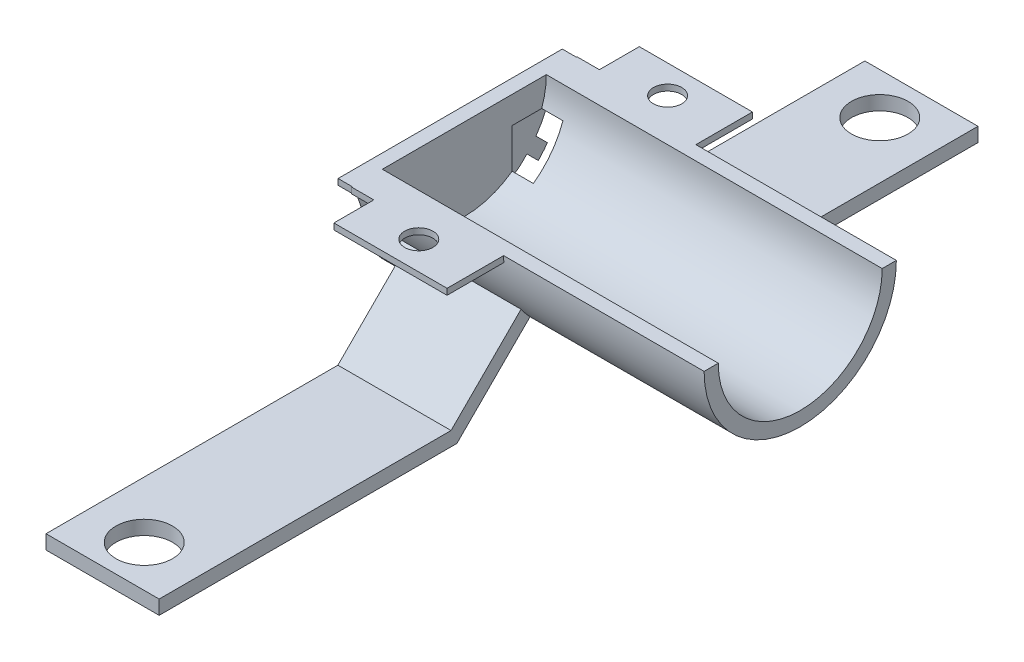
from build123d import *

# Parameters (mm, degrees)
BOSS_EXTRUDE2_DEPTH = 25.4
SKETCH5_R           = 6.35
CUT_EXTRUDE3_DEPTH  = 25.4
SKETCH6_R           = 6.35
CUT_EXTRUDE4_DEPTH  = 25.4
SKETCH7_R           = 3.175
CUT_EXTRUDE5_DEPTH  = 3.175
SKETCH8_R           = 3.175
CUT_EXTRUDE6_DEPTH  = 3.175
BOSS_EXTRUDE3_DEPTH = 5
BOSS_EXTRUDE4_DEPTH = 3.175
SKETCH12_W          = 6.35
SKETCH12_H          = 12.7
CUT_EXTRUDE7_DEPTH  = 74.175
BOSS_EXTRUDE5_DEPTH = 45


with BuildPart() as part:
    # Sketch4 → Boss-Extrude2 (new body)
    with BuildSketch(Plane(origin=(0, 0, 0), x_dir=(0, 0, -1), z_dir=(1, 0, 0))):
        with BuildLine():
            Line((-95.034446017, -11.155981989), (-95.034446017, -14.330981989))
            Line((-95.034446017, -14.330981989), (-28.199126576, -14.330981989))
            Line((-28.199126576, -14.330981989), (-11.780407797, 2.08773679))
            ThreePointArc((-11.780407797, 2.08773679), (3.868526207, -4.634940512), (19.517460211, 2.08773679))
            Line((19.517460211, 2.08773679), (35.93617899, -14.330981989))
            Line((35.93617899, -14.330981989), (88.77149843, -14.330981989))
            Line((88.77149843, -14.330981989), (88.77149843, -11.155981989))
            Line((88.77149843, -11.155981989), (37.251307051, -11.155981989))
            Line((37.251307051, -11.155981989), (21.536971904, 4.558353157))
            ThreePointArc((21.536971904, 4.558353157), (24.227085542, 9.797952879), (25.399969977, 15.569820752))
            Line((25.399969977, 15.569820752), (38.143526207, 15.569820752))
            Line((38.143526207, 15.569820752), (38.143526207, 16.940059488))
            Line((38.143526207, 16.940059488), (22.268526207, 16.940059488))
            ThreePointArc((22.268526207, 16.940059488), (3.868526207, -1.459940512), (-14.531473793, 16.940059488))
            Line((-14.531473793, 16.940059488), (-30.406473793, 16.940059488))
            Line((-30.406473793, 16.940059488), (-30.406473793, 15.569820752))
            Line((-30.406473793, 15.569820752), (-17.662917563, 15.569820752))
            ThreePointArc((-17.662917563, 15.569820752), (-16.490033128, 9.797952879), (-13.79991949, 4.558353157))
            Line((-13.79991949, 4.558353157), (-29.514254637, -11.155981989))
            Line((-29.514254637, -11.155981989), (-95.034446017, -11.155981989))
        make_face()
    extrude(amount=BOSS_EXTRUDE2_DEPTH)

    # Sketch5 → Cut-Extrude3 (cut)
    with BuildSketch(Plane(origin=(0, -11.155981989, 0), x_dir=(1, 0, 0), z_dir=(0, 1, 0))):
        with Locations(Location((12.7, -85.684446017, 0), (0, 0, 270))):
            Circle(SKETCH5_R)
    extrude(amount=-CUT_EXTRUDE3_DEPTH, mode=Mode.SUBTRACT)

    # Sketch6 → Cut-Extrude4 (cut)
    with BuildSketch(Plane(origin=(0, -11.155981989, 0), x_dir=(1, 0, 0), z_dir=(0, 1, 0))):
        with Locations(Location((12.7, 79.42149843, 0), (0, 0, 270))):
            Circle(SKETCH6_R)
    extrude(amount=-CUT_EXTRUDE4_DEPTH, mode=Mode.SUBTRACT)

    # Sketch7 → Cut-Extrude5 (cut)
    with BuildSketch(Plane(origin=(0, 16.940059488, 0), x_dir=(1, 0, 0), z_dir=(0, 1, 0))):
        with Locations(Location((12.7, -24.056473793, 0), (0, 0, 270))):
            Circle(SKETCH7_R)
    extrude(amount=-CUT_EXTRUDE5_DEPTH, mode=Mode.SUBTRACT)

    # Sketch8 → Cut-Extrude6 (cut)
    with BuildSketch(Plane(origin=(0, 16.940059488, 0), x_dir=(1, 0, 0), z_dir=(0, 1, 0))):
        with Locations(Location((12.7, 31.793526207, 0), (0, 0, 270))):
            Circle(SKETCH8_R)
    extrude(amount=-CUT_EXTRUDE6_DEPTH, mode=Mode.SUBTRACT)

    # Sketch10 → Boss-Extrude3 (add)
    with BuildSketch(Plane.ZY):
        with BuildLine():
            Line((-22.268526207, 16.940059488), (-29.184168721, 16.940059488))
            ThreePointArc((-29.184168721, 16.940059488), (-29.174889499, 16.254688903), (-29.147058635, 15.569820752))
            Line((-29.147058635, 15.569820752), (-25.399969977, 15.569820752))
            ThreePointArc((-25.399969977, 15.569820752), (-24.227085542, 9.797952879), (-21.536971904, 4.558353157))
            Line((-21.536971904, 4.558353157), (-24.216513217, 1.878811845))
            ThreePointArc((-24.216513217, 1.878811845), (-23.228268183, 0.628034888), (-22.163262525, -0.558065525))
            Line((-22.163262525, -0.558065525), (-19.517460211, 2.08773679))
            ThreePointArc((-19.517460211, 2.08773679), (-3.868526207, -4.634940512), (11.780407797, 2.08773679))
            Line((11.780407797, 2.08773679), (14.426210111, -0.558065525))
            ThreePointArc((14.426210111, -0.558065525), (15.491215769, 0.628034888), (16.479460803, 1.878811845))
            Line((16.479460803, 1.878811845), (13.79991949, 4.558353157))
            ThreePointArc((13.79991949, 4.558353157), (16.490033128, 9.797952879), (17.662917563, 15.569820752))
            Line((17.662917563, 15.569820752), (21.410006221, 15.569820752))
            ThreePointArc((21.410006221, 15.569820752), (21.437837085, 16.254688903), (21.447116307, 16.940059488))
            Line((21.447116307, 16.940059488), (14.531473793, 16.940059488))
            ThreePointArc((14.531473793, 16.940059488), (-3.868526207, -1.459940512), (-22.268526207, 16.940059488))
        make_face()
    extrude(amount=BOSS_EXTRUDE3_DEPTH)

    # Sketch11 → Boss-Extrude4 (add)
    with BuildSketch(Plane.ZY.offset(5)):
        with BuildLine():
            Line((21.297794872, 16.940059488), (-29.034847286, 16.940059488))
            ThreePointArc((-29.034847286, 16.940059488), (-29.025512905, 16.254685909), (-28.997516686, 15.569820752))
            Line((-28.997516686, 15.569820752), (-25.399969977, 15.569820752))
            ThreePointArc((-25.399969977, 15.569820752), (-24.227085542, 9.797952879), (-21.536971904, 4.558353157))
            Line((-21.536971904, 4.558353157), (-24.109749596, 1.985575465))
            ThreePointArc((-24.109749596, 1.985575465), (-23.122328229, 0.734047506), (-22.057650024, -0.452453023))
            Line((-22.057650024, -0.452453023), (-19.517460211, 2.08773679))
            ThreePointArc((-19.517460211, 2.08773679), (-3.868526207, -4.634940512), (11.780407797, 2.08773679))
            Line((11.780407797, 2.08773679), (14.32059761, -0.452453023))
            ThreePointArc((14.32059761, -0.452453023), (15.385275816, 0.734047506), (16.372697182, 1.985575465))
            Line((16.372697182, 1.985575465), (13.79991949, 4.558353157))
            ThreePointArc((13.79991949, 4.558353157), (16.490033128, 9.797952879), (17.662917563, 15.569820752))
            Line((17.662917563, 15.569820752), (21.260464272, 15.569820752))
            ThreePointArc((21.260464272, 15.569820752), (21.288460491, 16.254685909), (21.297794872, 16.940059488))
        make_face()
    extrude(amount=BOSS_EXTRUDE4_DEPTH)

    # Sketch12 → Cut-Extrude7 (cut)
    with BuildSketch(Plane(origin=(0, 0, -88.77149843), x_dir=(-1, 0, 0), z_dir=(0, 0, -1))):
        with Locations((3.4125, 4.519997663)):
            Rectangle(SKETCH12_W, SKETCH12_H)
    extrude(amount=-CUT_EXTRUDE7_DEPTH, mode=Mode.SUBTRACT)

    # Sketch13 → Boss-Extrude5 (add)
    with BuildSketch(Plane(origin=(25.4, 0, 0), x_dir=(0, 0, -1), z_dir=(1, 0, 0))):
        with BuildLine():
            Line((-14.531473793, 16.940059488), (-17.706473793, 16.940059488))
            ThreePointArc((-17.706473793, 16.940059488), (-17.695581986, 16.254594073), (-17.662917563, 15.569820752))
            ThreePointArc((-17.662917563, 15.569820752), (-16.490033128, 9.797952879), (-13.79991949, 4.558353157))
            ThreePointArc((-13.79991949, 4.558353157), (-12.835902363, 3.285657591), (-11.780407797, 2.08773679))
            ThreePointArc((-11.780407797, 2.08773679), (3.868526207, -4.634940512), (19.517460211, 2.08773679))
            ThreePointArc((19.517460211, 2.08773679), (20.572954777, 3.285657591), (21.536971904, 4.558353157))
            ThreePointArc((21.536971904, 4.558353157), (24.227085542, 9.797952879), (25.399969977, 15.569820752))
            ThreePointArc((25.399969977, 15.569820752), (25.4326344, 16.254594073), (25.443526207, 16.940059488))
            Line((25.443526207, 16.940059488), (22.268526207, 16.940059488))
            ThreePointArc((22.268526207, 16.940059488), (3.868526207, -1.459940512), (-14.531473793, 16.940059488))
        make_face()
    extrude(amount=BOSS_EXTRUDE5_DEPTH)


solid = part.part
